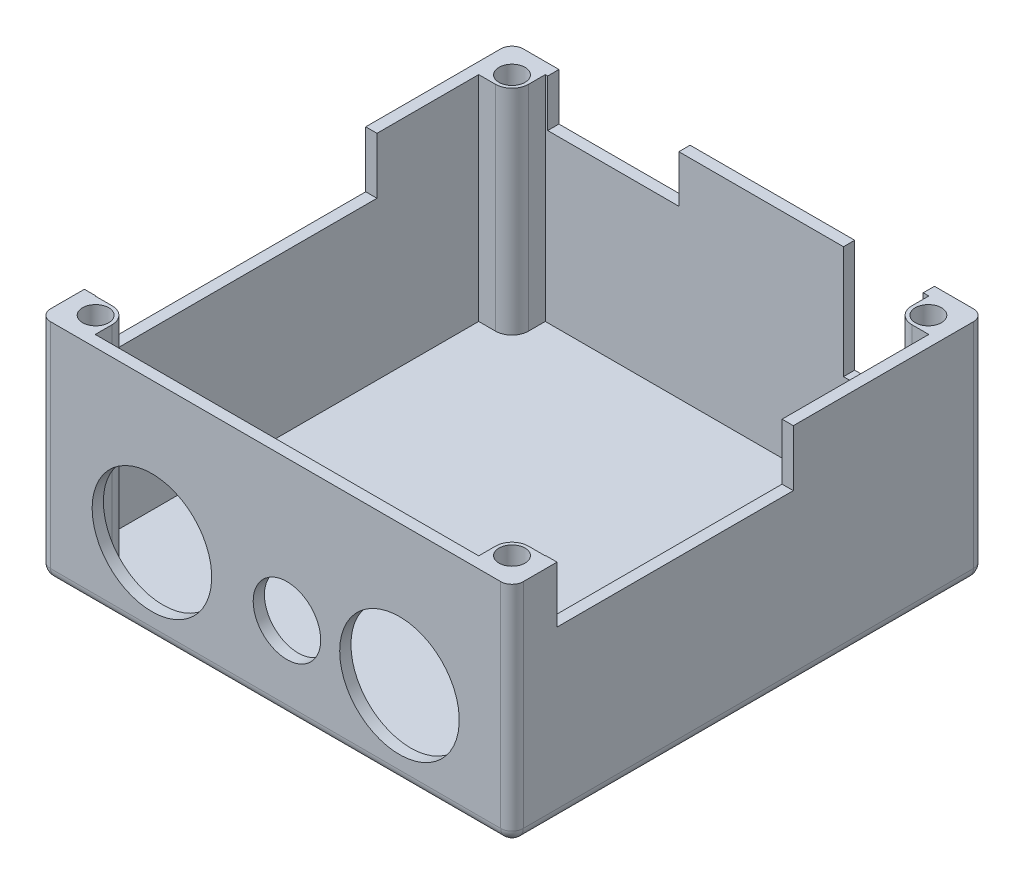
from build123d import *

# Parameters (mm, degrees)
SKETCH4_W                        = 53.34
SKETCH4_H                        = 53.34
BOSS_EXTRUDE2_DEPTH              = 25.4
SHELL1_T                         = -1.27
SKETCH13_W                       = 14.8000212
SKETCH13_H                       = 5.334
SKETCH13_W_2                     = 8.999982
SKETCH13_H_2                     = 12.7
CUT_EXTRUDE5_DEPTH               = 1.27
F_1_2_CLEARANCE_HOLE2_D          = 13.49248
F_1_2_CLEARANCE_HOLE2_DEPTH      = 1.27
F_97_0_0059_DIAMETER_HOLE1_D     = 7.62
F_97_0_0059_DIAMETER_HOLE1_DEPTH = 1.27
FILLET2_R                        = 1.27
CUT_EXTRUDE6_REACH               = 55.34
SKETCH24_W                       = 31.75
SKETCH24_H                       = 6.35
CUT_EXTRUDE7_REACH               = 55.34
SKETCH26_W                       = 26.67
SKETCH26_H                       = 6.35
SKETCH27_R                       = 1.4732
BOSS_EXTRUDE3_DEPTH              = 24.13
SKETCH28_R                       = 1.4732
CUT_EXTRUDE8_DEPTH               = 26.4
BODY_MOVE_COPY1_ANGLE            = 180


with BuildPart() as part:
    # Sketch4 → Boss-Extrude2 (new body)
    with BuildSketch(Plane(origin=(0, 0, 0), x_dir=(1, 0, 0), z_dir=(0, 1, 0))):
        with Locations((25.4, 25.4)):
            Rectangle(SKETCH4_W, SKETCH4_H)
    extrude(amount=BOSS_EXTRUDE2_DEPTH)

    # Shell1
    shell1_openings = [part.faces().sort_by_distance(p)[0] for p in [
        (25.4, 0, -25.4),
    ]]
    offset(amount=SHELL1_T, openings=shell1_openings, kind=Kind.INTERSECTION)

    # Sketch13 → Cut-Extrude5 (cut)
    with BuildSketch(Plane(origin=(0, 0, -52.07), x_dir=(-1, 0, 0), z_dir=(0, 0, -1))):
        with Locations((-39.37, 2.667)):
            Rectangle(SKETCH13_W, SKETCH13_H)
        with Locations((-8.89, 6.35)):
            Rectangle(SKETCH13_W_2, SKETCH13_H_2)
    extrude(amount=-CUT_EXTRUDE5_DEPTH, mode=Mode.SUBTRACT)

    # 1/2 Clearance Hole2
    with Locations(Plane.XY.offset(1.27)):
        with Locations((11.43, 15.875), (39.37, 15.875)):
            Hole(F_1_2_CLEARANCE_HOLE2_D / 2, depth=F_1_2_CLEARANCE_HOLE2_DEPTH)

    # #97 (0.0059) Diameter Hole1
    with Locations(Plane.XY.offset(1.27)):
        with Locations((24.13, 15.875)):
            Hole(F_97_0_0059_DIAMETER_HOLE1_D / 2, depth=F_97_0_0059_DIAMETER_HOLE1_DEPTH)

    # Fillet2
    fillet2_edges = [part.edges().sort_by_distance(p)[0] for p in [
        (52.07, 25.4, -25.4),
        (25.4, 25.4, -52.07),
        (-1.27, 25.4, -25.4),
        (25.4, 25.4, 1.27),
        (-1.27, 12.7, -52.07),
        (52.07, 12.7, -52.07),
        (52.07, 12.7, 1.27),
        (-1.27, 12.7, 1.27),
    ]]
    fillet(fillet2_edges, radius=FILLET2_R)

    # Sketch24 → Cut-Extrude6 (cut, up to next)
    with BuildSketch(Plane(origin=(52.07, 0, 0), x_dir=(0, 0, -1), z_dir=(1, 0, 0)), mode=Mode.PRIVATE) as cut_extrude6_sk1:
        with Locations((19.685, 3.175)):
            Rectangle(SKETCH24_W, SKETCH24_H)
    cut_extrude6_tool1 = extrude(cut_extrude6_sk1.sketch, amount=-CUT_EXTRUDE6_REACH, mode=Mode.PRIVATE) & part.part
    add(cut_extrude6_tool1.solids().sort_by_distance((52.07, 3.175, -19.685))[0], mode=Mode.SUBTRACT)

    # Sketch26 → Cut-Extrude7 (cut, up to next)
    with BuildSketch(Plane.ZY.offset(1.27), mode=Mode.PRIVATE) as cut_extrude7_sk1:
        with Locations((-17.145, 3.175)):
            Rectangle(SKETCH26_W, SKETCH26_H)
    cut_extrude7_tool1 = extrude(cut_extrude7_sk1.sketch, amount=-CUT_EXTRUDE7_REACH, mode=Mode.PRIVATE) & part.part
    add(cut_extrude7_tool1.solids().sort_by_distance((-1.27, 3.175, -17.145))[0], mode=Mode.SUBTRACT)

    # Sketch27 → Boss-Extrude3 (add)
    with BuildSketch(Plane.XZ.offset(-24.13)):
        with BuildLine():
            Line((1.905, -3.7592), (0, -3.7592))
            Line((0, -3.7592), (0, 0))
            Line((0, 0), (3.7592, 0))
            Line((3.7592, 0), (3.7592, -1.905))
            ThreePointArc((3.7592, -1.905), (3.216117394, -3.216117394), (1.905, -3.7592))
        make_face()
        with Locations((1.905, -1.905)):
            Circle(SKETCH27_R, mode=Mode.SUBTRACT)
        with BuildLine():
            Line((0, -47.0408), (0, -50.8))
            Line((0, -50.8), (3.7592, -50.8))
            Line((3.7592, -50.8), (3.7592, -48.895))
            ThreePointArc((3.7592, -48.895), (3.216117394, -47.583882606), (1.905, -47.0408))
            Line((1.905, -47.0408), (0, -47.0408))
        make_face()
        with Locations((1.905, -48.895)):
            Circle(SKETCH27_R, mode=Mode.SUBTRACT)
        with BuildLine():
            Line((50.8, -50.8), (47.0408, -50.8))
            Line((47.0408, -50.8), (47.0408, -48.895))
            ThreePointArc((47.0408, -48.895), (47.583882606, -47.583882606), (48.895, -47.0408))
            Line((48.895, -47.0408), (50.8, -47.0408))
            Line((50.8, -47.0408), (50.8, -50.8))
        make_face()
        with Locations((48.895, -48.895)):
            Circle(SKETCH27_R, mode=Mode.SUBTRACT)
        with BuildLine():
            Line((47.0408, 0), (47.0408, -1.905))
            ThreePointArc((47.0408, -1.905), (47.583882606, -3.216117394), (48.895, -3.7592))
            Line((48.895, -3.7592), (50.8, -3.7592))
            Line((50.8, -3.7592), (50.8, 0))
            Line((50.8, 0), (47.0408, 0))
        make_face()
        with Locations((48.895, -1.905)):
            Circle(SKETCH27_R, mode=Mode.SUBTRACT)
    extrude(amount=BOSS_EXTRUDE3_DEPTH)

    # Sketch28 → Cut-Extrude8 (cut, through all)
    with BuildSketch(Plane.XZ):
        with Locations((48.895, -1.905)):
            Circle(SKETCH28_R)
        with Locations((1.905, -1.905)):
            Circle(SKETCH28_R)
        with Locations((1.905, -48.895)):
            Circle(SKETCH28_R)
        with Locations((48.895, -48.895)):
            Circle(SKETCH28_R)
    extrude(amount=-CUT_EXTRUDE8_DEPTH, mode=Mode.SUBTRACT)


with BuildPart() as part_1:
    # Body-Move/Copy1: moved
    add(part.part.rotate(Axis((25.4, 12.7, 0), (0, 0, 1)), BODY_MOVE_COPY1_ANGLE))


solid = part_1.part
